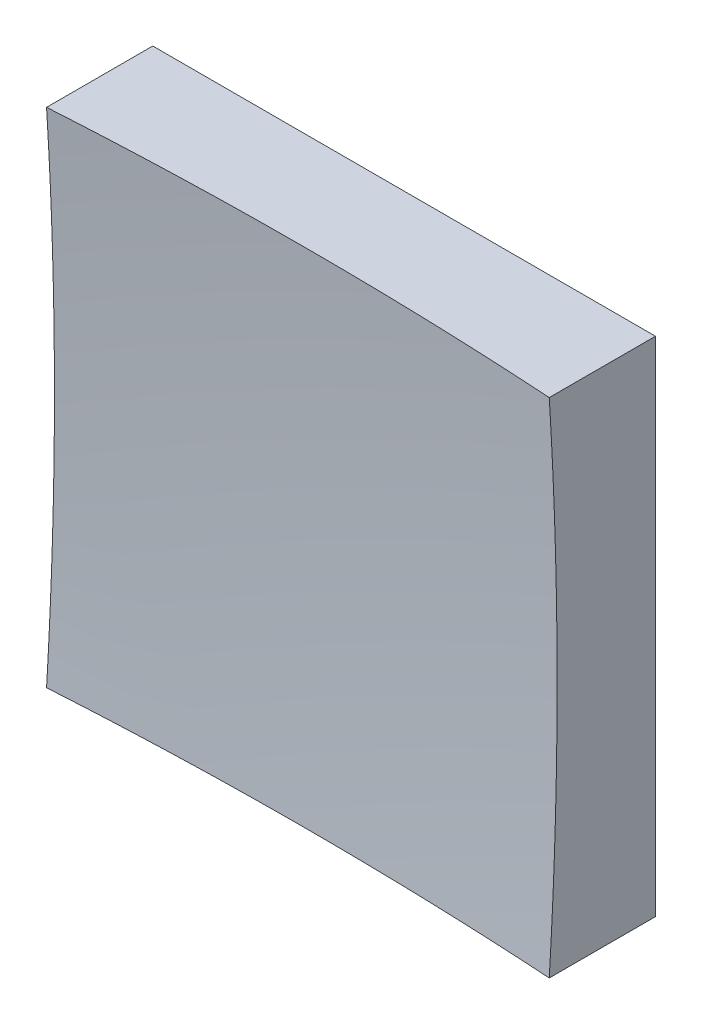
from build123d import *

# Parameters (mm, degrees)
SKETCH_1_W      = 50
SKETCH_1_H      = 50
EXTRUDE_1_DEPTH = 50


with BuildPart() as part:
    # 草图1 → 凸台-拉伸1 (new body)
    with BuildSketch(Plane.XY):
        Rectangle(SKETCH_1_W, SKETCH_1_H)
    extrude(amount=EXTRUDE_1_DEPTH)

    # 草图2 → 切除-旋转2 (revolve, cut)
    with BuildSketch(Plane(origin=(0, 0, 0), x_dir=(1, 0, 0), z_dir=(0, 1, 0))):
        with BuildLine():
            Line((389.938184725, -319.847254146), (0, -319.847254146))
            Line((0, -319.847254146), (0, -9))
            ThreePointArc((0, -9), (249.338025237, -96.221245653), (389.938184725, -319.847254146))
        make_face()
    revolve(axis=Axis((0, 0, 319.847254146), (0, 0, -1)), mode=Mode.SUBTRACT)


solid = part.part
